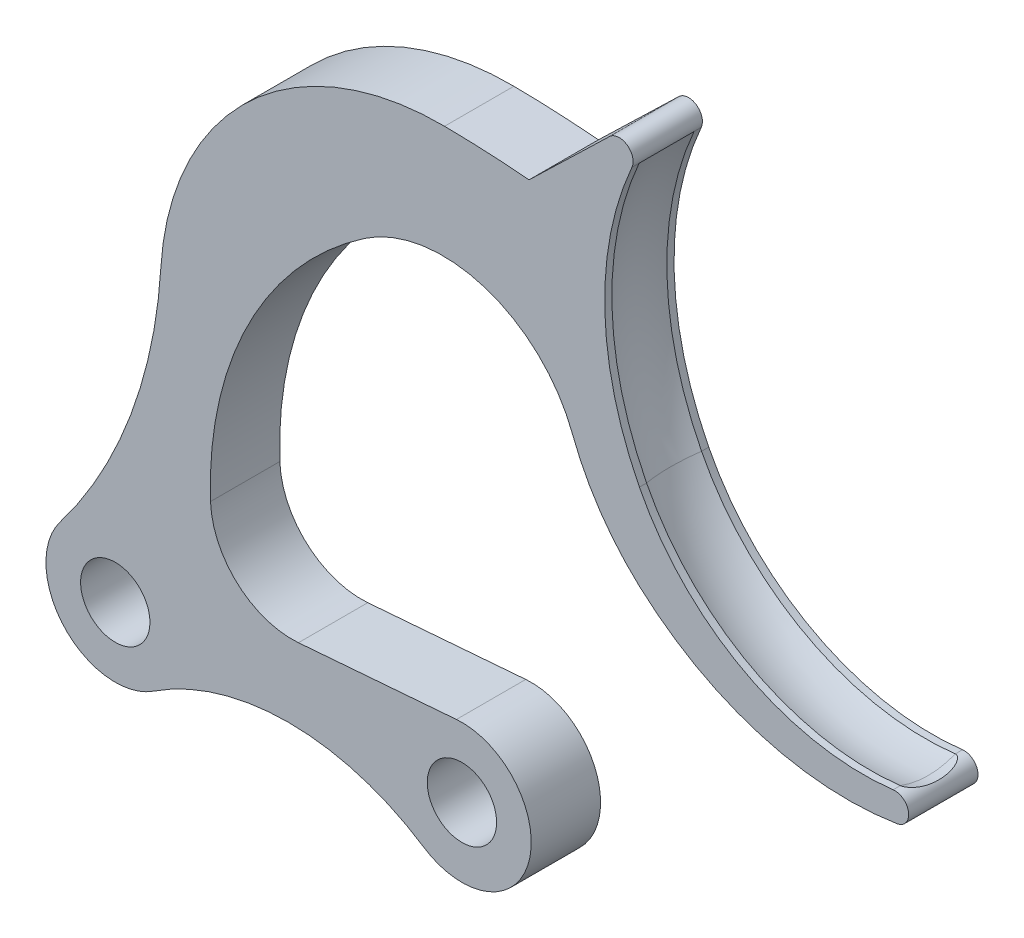
from build123d import *

# Parameters (mm, degrees)
SKETCH_1_R          = 2.5
EXTRUDE_1_DEPTH     = 2.5
SKETCH_2_OUTSIDE_W  = 86.761
SKETCH_2_OUTSIDE_H  = 89.395
CUT_EXTRUDE_1_DEPTH = 5
EXTRUDE_3_DEPTH     = 5
SKETCH_9_R          = 6
FILLET_1_R          = 10
CUT_EXTRUDE_2_DEPTH = 10


with BuildPart() as part:
    # 草圖1 → 填料-伸長1 (new body, symmetric)
    with BuildSketch(Plane.XY):
        with BuildLine():
            Line((0, -5), (25, -5))
            ThreePointArc((25, -5), (29.31444757, -2.526963033), (29.360979806, 2.445783133))
            Line((29.360979806, 2.445783133), (15.064071346, 27.938038866))
            Line((15.064071346, 27.938038866), (44.994741867, 27.938038866))
            Line((44.994741867, 27.938038866), (44.994741867, 63.392785695))
            Line((44.994741867, 63.392785695), (-20.763646925, 63.392785695))
            Line((-20.763646925, 63.392785695), (-20.763646925, 27.938038866))
            Line((-20.763646925, 27.938038866), (-1.414273127, 27.938038866))
            Line((-1.414273127, 27.938038866), (-4.9583743, 0.643835616))
            ThreePointArc((-4.9583743, 0.643835616), (-3.756273292, -3.300062266), (0, -5))
        make_face()
        with Locations((25, 0)):
            Circle(SKETCH_1_R, mode=Mode.SUBTRACT)
        Circle(SKETCH_1_R, mode=Mode.SUBTRACT)
    extrude(amount=EXTRUDE_1_DEPTH, both=True)

    # 草圖2 outside → 除料-伸長1 (cut)
    with BuildSketch(Plane.XY.offset(2.5)):
        with Locations((12.1155, 29.1965)):
            Rectangle(SKETCH_2_OUTSIDE_W, SKETCH_2_OUTSIDE_H)
        with BuildLine():
            Line((31.958651871, 36.150509371), (34.562055634, 40.749856019))
            ThreePointArc((34.562055634, 40.749856019), (29.16979084, 41.362709118), (23.748184909, 41.60415823))
            ThreePointArc((23.748184909, 41.60415823), (9.709628086, 36.160280684), (3.287148618, 22.5415936))
            ThreePointArc((3.287148618, 22.5415936), (1.109618969, 12.24710035), (-3.974011943, 3.034341622))
            ThreePointArc((-3.974011943, 3.034341622), (-3.656567639, -3.410207194), (2.750229007, -4.17567245))
            ThreePointArc((2.750229007, -4.17567245), (12.5, -1.253368592), (22.249770993, -4.17567245))
            ThreePointArc((22.249770993, -4.17567245), (29.842584669, -1.244738415), (24.604254755, 4.984313965))
            Line((24.604254755, 4.984313965), (13.210184283, 4.079645991))
            ThreePointArc((13.210184283, 4.079645991), (8.834388462, 5.55019775), (6.86933477, 9.727358931))
            ThreePointArc((6.86933477, 9.727358931), (13.861035744, 28.211579962), (31.958651871, 36.150509371))
        make_face(mode=Mode.SUBTRACT)
    extrude(amount=-CUT_EXTRUDE_1_DEPTH, mode=Mode.SUBTRACT)

    # 草圖6 → 填料-伸長3 (add)
    with BuildSketch(Plane.XY.offset(2.5)):
        with BuildLine():
            Line((29.843670315, 41.306571089), (35.648712263, 46.914150559))
            ThreePointArc((35.648712263, 46.914150559), (36.916127955, 47.014718803), (37.257884128, 45.79011306))
            ThreePointArc((37.257884128, 45.79011306), (35.304038414, 35.87931312), (37.799168171, 26.090758784))
            ThreePointArc((37.799168171, 26.090758784), (45.415881251, 18.337037181), (56.099880608, 16.340371315))
            ThreePointArc((56.099880608, 16.340371315), (57.209900526, 15.486647675), (56.377991211, 14.360186329))
            ThreePointArc((56.377991211, 14.360186329), (46.455950686, 15.010232793), (37.799168171, 19.902018262))
            ThreePointArc((37.799168171, 19.902018262), (32.860967015, 27.300914678), (31.958651871, 36.150509371))
            Line((31.958651871, 36.150509371), (34.562055634, 40.749856019))
            ThreePointArc((34.562055634, 40.749856019), (32.207046263, 41.063668613), (29.843670315, 41.306571089))
        make_face()
    extrude(amount=-EXTRUDE_3_DEPTH)

    # 除料-掃出3: sweep along a path in 草圖16
    with BuildLine(Plane.XY) as sweep_3_path:
        ThreePointArc((56.099880608, 16.340371315), (45.415881251, 18.337037181), (37.799168171, 26.090758784))
        ThreePointArc((37.799168171, 26.090758784), (35.304038414, 35.87931312), (37.257884128, 45.79011306))
    # 草圖9 → 除料-掃出3 (sweep, cut)
    with BuildSketch(Plane(origin=(37.257884128, 45.79011306, 2.5), x_dir=(0.914403512, -0.404803924, 0), z_dir=(0.404803924, 0.914403512, 0))):
        with Locations((5.663169824, 2.5)):
            Circle(SKETCH_9_R)
    sweep(path=sweep_3_path.line, mode=Mode.SUBTRACT)

    # 圓角1
    fillet_1_edges = [part.edges().sort_by_distance(p)[0] for p in [
        (31.958651871, 36.150509371, 0),
    ]]
    fillet(fillet_1_edges, radius=FILLET_1_R)

    # 草圖20 → 除料-伸長2 (cut)
    with BuildSketch(Plane(origin=(57.238055568, 6.903294961, 0), x_dir=(0, 0, 1), z_dir=(-0.992805403, -0.119739017, 0))):
        with BuildLine():
            Line((1.982046302, 9.505464342), (-1.982046302, 9.505464342))
            ThreePointArc((-1.982046302, 9.505464342), (-1.005231579, 9.25344106), (0, 9.168634166))
            ThreePointArc((0, 9.168634166), (1.005231579, 9.25344106), (1.982046302, 9.505464342))
        make_face()
    extrude(amount=-CUT_EXTRUDE_2_DEPTH, mode=Mode.SUBTRACT)


solid = part.part
